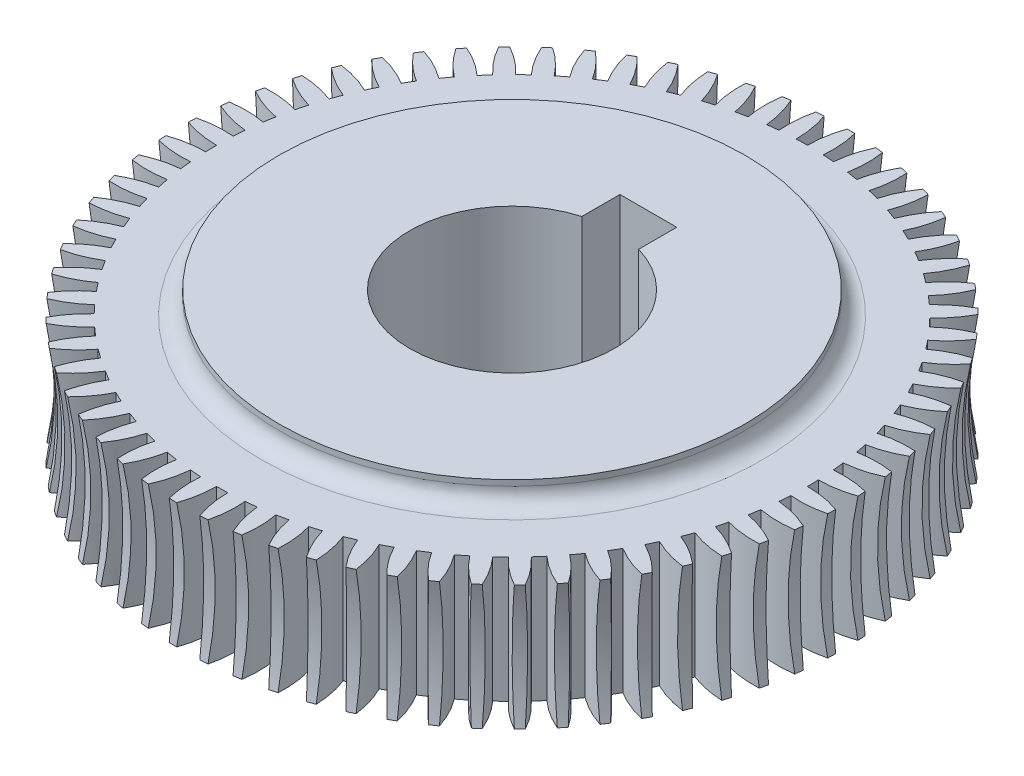
from build123d import *

# Parameters (mm, degrees)
CUT_EXTRUDE1_START  = -12
CUT_EXTRUDE1_DEPTH  = 13
CIRPATTERN1_COUNT   = 68
CUT_EXTRUDE2_DEPTH  = 12.0000001
SKETCH4_R           = 20.5
BOSS_EXTRUDE1_DEPTH = 2
FILLET1_R           = 1.5
FILLET2_R           = 1.5


with BuildPart() as part:
    # Sketch1 → Revolve1 (revolve)
    with BuildSketch(Plane.XY):
        with BuildLine():
            Line((8.658241762, -5.5), (37.658241762, -5.5))
            ThreePointArc((37.658241762, -5.5), (37.149765968, 0), (37.658241762, 5.5))
            Line((37.658241762, 5.5), (8.658241762, 5.5))
            Line((8.658241762, 5.5), (8.658241762, -5.5))
        make_face()
    revolve(axis=Axis((8.658241762, 5.5, 0), (0, -1, 0)))

    # Sketch2 → Cut-Extrude1 (cut)
    with BuildSketch(Plane(origin=(0, 5.5, 0), x_dir=(1, 0, 0), z_dir=(0, 1, 0)).offset(CUT_EXTRUDE1_START)):
        with BuildLine():
            ThreePointArc((9.631841137, -25.981764841), (9.145126827, -25.995440811), (8.658241762, -26))
            ThreePointArc((8.658241762, -26), (8.52903557, -27.519545066), (8.145126827, -28.995460215))
            ThreePointArc((8.145126827, -28.995460215), (9.145416635, -28.995907653), (10.145126827, -28.961857206))
            ThreePointArc((10.145126827, -28.961857206), (9.762425401, -27.493523124), (9.631841137, -25.981764841))
        make_face()
    cut_extrude1 = extrude(amount=CUT_EXTRUDE1_DEPTH, mode=Mode.SUBTRACT)

    # CirPattern1: Cut-Extrude1 ×68 about axis
    cirpattern1_axis = Axis((8.658241762, 5.5, 0), (0, 1, 0))
    for i in range(1, CIRPATTERN1_COUNT):
        add(cut_extrude1.rotate(cirpattern1_axis, i * 360 / CIRPATTERN1_COUNT), mode=Mode.SUBTRACT)

    # Sketch3 → Cut-Extrude2 (cut, through all)
    with BuildSketch(Plane(origin=(0, 5.5, 0), x_dir=(1, 0, 0), z_dir=(0, 1, 0))):
        with BuildLine():
            Line((6.158241762, 8.645808233), (6.158241762, 12))
            Line((6.158241762, 12), (11.158241762, 12))
            Line((11.158241762, 12), (11.158241762, 8.645808233))
            ThreePointArc((11.158241762, 8.645808233), (8.658241762, -9), (6.158241762, 8.645808233))
        make_face()
    extrude(amount=-CUT_EXTRUDE2_DEPTH, mode=Mode.SUBTRACT)

    # Sketch4 → Boss-Extrude1 (add)
    with BuildSketch(Plane(origin=(0, 5.5, 0), x_dir=(1, 0, 0), z_dir=(0, 1, 0))):
        with Locations((8.658241762, 0)):
            Circle(SKETCH4_R)
        with BuildLine():
            Line((6.158241762, 8.645808233), (6.158241762, 12))
            Line((6.158241762, 12), (11.158241762, 12))
            Line((11.158241762, 12), (11.158241762, 8.645808233))
            ThreePointArc((11.158241762, 8.645808233), (8.658241762, -9), (6.158241762, 8.645808233))
        make_face(mode=Mode.SUBTRACT)
    boss_extrude1 = extrude(amount=BOSS_EXTRUDE1_DEPTH)

    # Fillet1
    fillet1_edges = [part.edges().sort_by_distance(p)[0] for p in [
        (-11.841758238, 5.5, 0),
    ]]
    fillet(fillet1_edges, radius=FILLET1_R)

    # Mirror7: Boss-Extrude1 across plane
    add(boss_extrude1.mirror(Plane.ZX))

    # Fillet2
    fillet2_edges = [part.edges().sort_by_distance(p)[0] for p in [
        (-11.841758238, -5.5, 0),
    ]]
    fillet(fillet2_edges, radius=FILLET2_R)


solid = part.part
